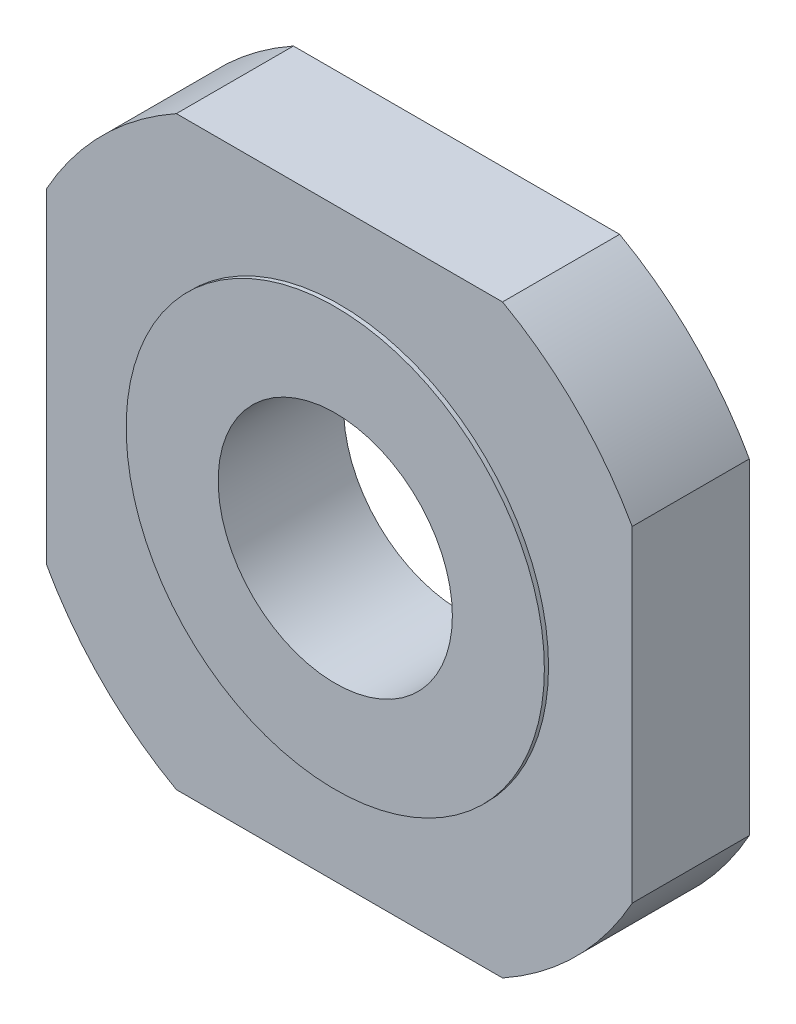
from build123d import *

# Parameters (mm, degrees)
SKETCH1_R           = 14
BOSS_EXTRUDE1_DEPTH = 7
SKETCH2_R           = 25
SKETCH2_R_2         = 14
BOSS_EXTRUDE2_DEPTH = 7.5


with BuildPart() as part:
    # Sketch1 → Boss-Extrude1 (new body, symmetric)
    with BuildSketch(Plane.XY):
        with BuildLine():
            Line((-19.5, 35), (19.5, 35))
            ThreePointArc((19.5, 35), (28.332479027, 28.332479027), (35, 19.5))
            Line((35, 19.5), (35, -19.5))
            ThreePointArc((35, -19.5), (28.332479027, -28.332479027), (19.5, -35))
            Line((19.5, -35), (-19.5, -35))
            ThreePointArc((-19.5, -35), (-28.332479027, -28.332479027), (-35, -19.5))
            Line((-35, -19.5), (-35, 19.5))
            ThreePointArc((-35, 19.5), (-28.332479027, 28.332479027), (-19.5, 35))
        make_face()
        with Locations((-0.04820778, -0.04820778)):
            Circle(SKETCH1_R, mode=Mode.SUBTRACT)
    extrude(amount=BOSS_EXTRUDE1_DEPTH, both=True)

    # Sketch2 → Boss-Extrude2 (add, symmetric)
    with BuildSketch(Plane.XY):
        Circle(SKETCH2_R)
        Circle(SKETCH2_R_2, mode=Mode.SUBTRACT)
    extrude(amount=BOSS_EXTRUDE2_DEPTH, both=True)


solid = part.part
